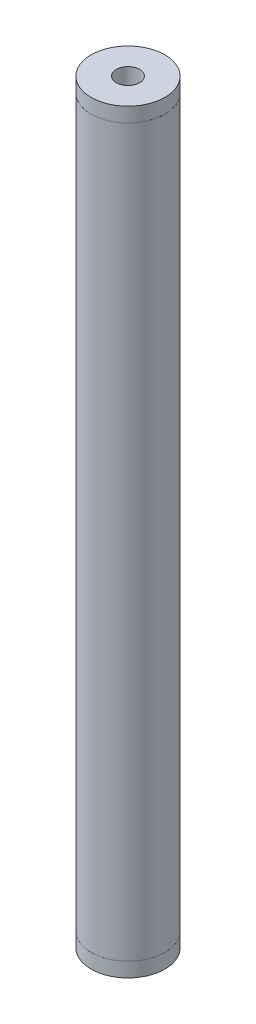
from build123d import *

# Parameters (mm, degrees)
ESBO_O1_R                = 25.4
ESBO_O1_R_2              = 21.65
RESSALTO_EXTRUS_O1_DEPTH = 500


with BuildPart() as part:
    # Esboço1 → Ressalto-extrusão1 (new body)
    with BuildSketch(Plane(origin=(0, 0, 0), x_dir=(1, 0, 0), z_dir=(0, 1, 0))):
        Circle(ESBO_O1_R)
        Circle(ESBO_O1_R_2, mode=Mode.SUBTRACT)
    extrude(amount=RESSALTO_EXTRUS_O1_DEPTH)


with BuildPart() as body_2:
    # Esboço2 → Revolução1 (revolve)
    with BuildSketch(Plane.XY):
        Polygon((25.4, 500), (25.4, 510), (8, 510), (8, 460), (21.65, 460), (21.65, 500), align=None)
        Polygon((8, -10), (8, 40), (21.65, 40), (21.65, 0), (25.4, 0), (25.4, -10), align=None)
    revolve(axis=Axis((0, 0, 0), (0, 1, 0)))


solid = Compound([part.part, body_2.part])
